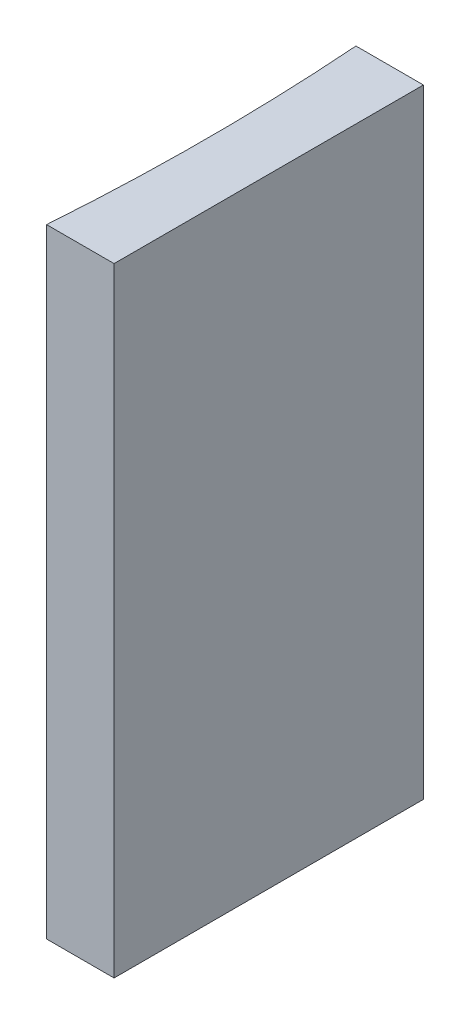
from build123d import *

# Parameters (mm, degrees)
EXTRUDE_1_DEPTH = 20


with BuildPart() as part:
    # 草图1 → 凸台-拉伸1 (new body)
    with BuildSketch(Plane(origin=(0, 0, 0), x_dir=(1, 0, 0), z_dir=(0, 1, 0))):
        with BuildLine():
            Line((0, 0), (0, -10))
            Line((0, -10), (-2.18197962, -10))
            ThreePointArc((-2.18197962, -10), (-2, -5), (-2.18197962, 0))
            Line((-2.18197962, 0), (0, 0))
        make_face()
    extrude(amount=EXTRUDE_1_DEPTH)


solid = part.part
